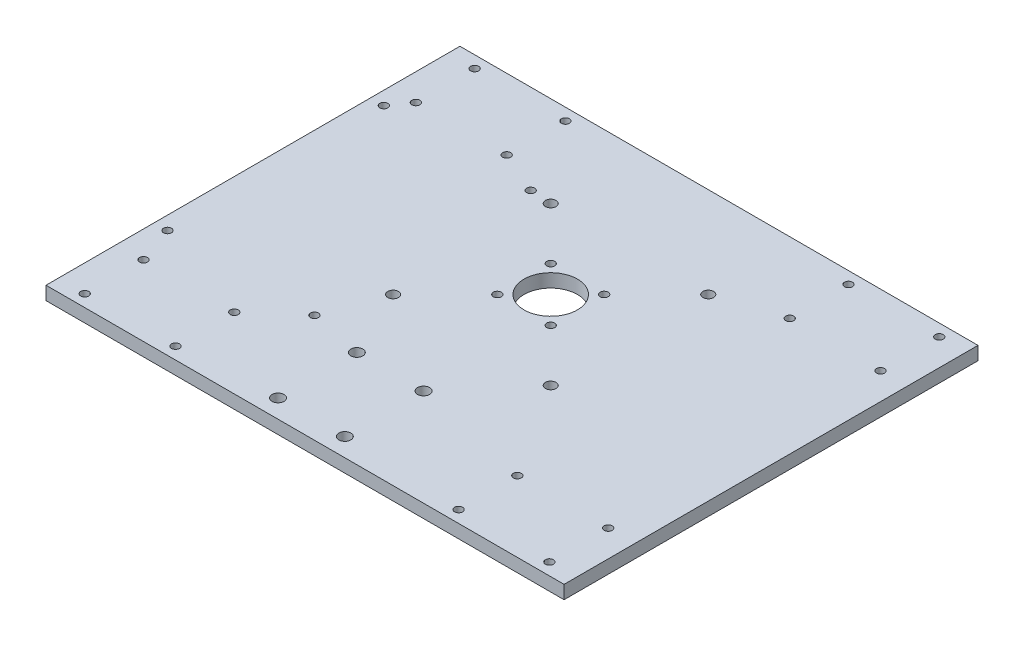
from build123d import *

# Parameters (mm, degrees)
SKETCH1_W           = 194
SKETCH1_H           = 155
BOSS_EXTRUDE1_DEPTH = 5
SKETCH2_R           = 2
CUT_EXTRUDE1_DEPTH  = 6
SKETCH3_R           = 10
SKETCH3_R_2         = 1.5
CUT_EXTRUDE2_DEPTH  = 6
SKETCH4_R           = 2.25
CUT_EXTRUDE3_DEPTH  = 6
SKETCH5_R           = 1.5
CUT_EXTRUDE4_DEPTH  = 6
SKETCH6_R           = 1.5
CUT_EXTRUDE5_DEPTH  = 6


with BuildPart() as part:
    # Sketch1 → Boss-Extrude1 (new body)
    with BuildSketch(Plane(origin=(0, 0, 0), x_dir=(1, 0, 0), z_dir=(0, 1, 0))):
        with Locations((97, 77.5)):
            Rectangle(SKETCH1_W, SKETCH1_H)
    extrude(amount=BOSS_EXTRUDE1_DEPTH)

    # Sketch2 → Cut-Extrude1 (cut, through all)
    with BuildSketch(Plane(origin=(0, 5, 0), x_dir=(1, 0, 0), z_dir=(0, 1, 0))):
        with Locations((68, 121)):
            Circle(SKETCH2_R)
        with Locations((127, 121)):
            Circle(SKETCH2_R)
        with Locations((68, 62)):
            Circle(SKETCH2_R)
        with Locations((127, 62)):
            Circle(SKETCH2_R)
    extrude(amount=-CUT_EXTRUDE1_DEPTH, mode=Mode.SUBTRACT)

    # Sketch3 → Cut-Extrude2 (cut, through all)
    with BuildSketch(Plane(origin=(0, 5, 0), x_dir=(1, 0, 0), z_dir=(0, 1, 0))):
        with Locations((97.5, 91.5)):
            Circle(SKETCH3_R)
        with Locations((107.5, 101.5)):
            Circle(SKETCH3_R_2)
        with Locations((107.5, 81.5)):
            Circle(SKETCH3_R_2)
        with Locations((87.5, 81.5)):
            Circle(SKETCH3_R_2)
        with Locations((87.5, 101.5)):
            Circle(SKETCH3_R_2)
    extrude(amount=-CUT_EXTRUDE2_DEPTH, mode=Mode.SUBTRACT)

    # Sketch4 → Cut-Extrude3 (cut, through all)
    with BuildSketch(Plane(origin=(0, 0, 0), x_dir=(-1, 0, 0), z_dir=(0, -1, 0))):
        with Locations((-80, 6.896410277)):
            Circle(SKETCH4_R)
        with Locations((-105, 6.896410277)):
            Circle(SKETCH4_R)
        with Locations((-80, 36.396410277)):
            Circle(SKETCH4_R)
        with Locations((-105, 36.396410277)):
            Circle(SKETCH4_R)
    extrude(amount=-CUT_EXTRUDE3_DEPTH, mode=Mode.SUBTRACT)

    # Sketch5 → Cut-Extrude4 (cut, through all)
    with BuildSketch(Plane(origin=(0, 5, 0), x_dir=(1, 0, 0), z_dir=(0, 1, 0))):
        with Locations((10, 4.5)):
            Circle(SKETCH5_R)
        with Locations((44, 4.5)):
            Circle(SKETCH5_R)
        with Locations((44, 26.5)):
            Circle(SKETCH5_R)
        with Locations((10, 26.5)):
            Circle(SKETCH5_R)
        with Locations((150, 4.5)):
            Circle(SKETCH5_R)
        with Locations((150, 26.5)):
            Circle(SKETCH5_R)
        with Locations((184, 26.5)):
            Circle(SKETCH5_R)
        with Locations((184, 4.5)):
            Circle(SKETCH5_R)
        with Locations((150, 128.5)):
            Circle(SKETCH5_R)
        with Locations((150, 150.5)):
            Circle(SKETCH5_R)
        with Locations((184, 150.5)):
            Circle(SKETCH5_R)
        with Locations((184, 128.5)):
            Circle(SKETCH5_R)
        with Locations((10, 128.5)):
            Circle(SKETCH5_R)
        with Locations((10, 150.5)):
            Circle(SKETCH5_R)
        with Locations((44, 150.5)):
            Circle(SKETCH5_R)
        with Locations((44, 128.5)):
            Circle(SKETCH5_R)
    extrude(amount=-CUT_EXTRUDE4_DEPTH, mode=Mode.SUBTRACT)

    # Sketch6 → Cut-Extrude5 (cut, through all)
    with BuildSketch(Plane(origin=(0, 5, 0), x_dir=(1, 0, 0), z_dir=(0, 1, 0))):
        with Locations((5, 121.5)):
            Circle(SKETCH6_R)
        with Locations((60, 121.5)):
            Circle(SKETCH6_R)
        with Locations((5, 40.5)):
            Circle(SKETCH6_R)
        with Locations((60, 40.5)):
            Circle(SKETCH6_R)
    extrude(amount=-CUT_EXTRUDE5_DEPTH, mode=Mode.SUBTRACT)


solid = part.part
